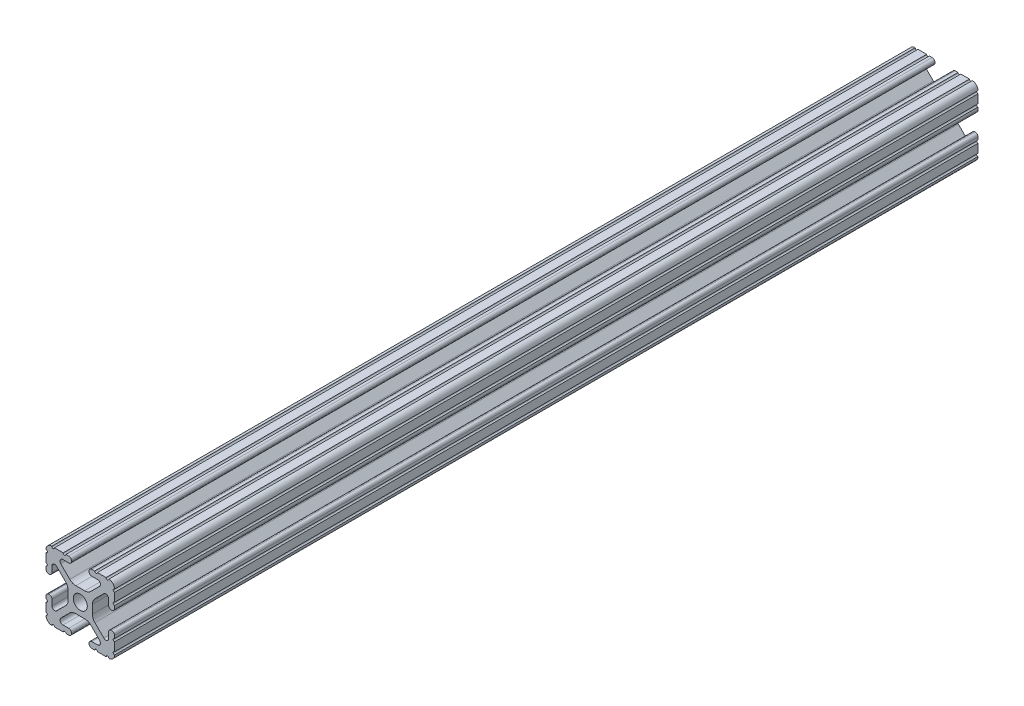
from build123d import *

# Parameters (mm, degrees)
SKETCH1_R      = 2.6035
EXTRUDE1_DEPTH = 160


with BuildPart() as part:
    # Sketch1 → Extrude1 (new body, symmetric)
    with BuildSketch(Plane.XY):
        with BuildLine():
            Line((-7.207036008, 8.724370562), (-3.898272566, 5.423169045))
            ThreePointArc((-3.898272566, 5.423169045), (-2.869120213, 4.736787962), (-1.655778399, 4.4958))
            Line((-1.655778399, 4.4958), (1.655778399, 4.4958))
            ThreePointArc((1.655778399, 4.4958), (2.869120213, 4.736787962), (3.898272566, 5.423169045))
            Line((3.898272566, 5.423169045), (7.207036008, 8.724370562))
            ThreePointArc((7.207036008, 8.724370562), (7.432222385, 9.85140422), (6.476788598, 10.4902))
            Line((6.476788598, 10.4902), (4.287512407, 10.4902))
            ThreePointArc((4.287512407, 10.4902), (3.54574862, 10.79744862), (3.2385, 11.539212407))
            Line((3.2385, 11.539212407), (3.2385, 11.650987593))
            ThreePointArc((3.2385, 11.650987593), (3.54574862, 12.39275138), (4.287512407, 12.7))
            Line((4.287512407, 12.7), (5.317126718, 12.7))
            ThreePointArc((5.317126718, 12.7), (5.825126718, 12.192), (6.333126718, 12.7))
            Line((6.333126718, 12.7), (9.550443118, 12.7))
            ThreePointArc((9.550443118, 12.7), (10.058366869, 12.192000006), (10.566443095, 12.699847501))
            ThreePointArc((10.566443095, 12.699847501), (12.082537762, 12.08250727), (12.699846982, 10.566399977))
            ThreePointArc((12.699846982, 10.566399977), (12.192000006, 10.058323491), (12.7, 9.5504))
            Line((12.7, 9.5504), (12.7, 6.3330836))
            ThreePointArc((12.7, 6.3330836), (12.192, 5.8250836), (12.7, 5.3170836))
            Line((12.7, 5.3170836), (12.7, 4.287469289))
            ThreePointArc((12.7, 4.287469289), (12.39275138, 3.545705502), (11.650987593, 3.238456882))
            Line((11.650987593, 3.238456882), (11.539212407, 3.238456882))
            ThreePointArc((11.539212407, 3.238456882), (10.79744862, 3.545705502), (10.4902, 4.287469289))
            Line((10.4902, 4.287469289), (10.4902, 6.402089023))
            ThreePointArc((10.4902, 6.402089023), (9.856505071, 7.351067942), (8.737131347, 7.129408934))
            Line((8.737131347, 7.129408934), (5.441005833, 3.840816462))
            ThreePointArc((5.441005833, 3.840816462), (4.750877967, 2.809883091), (4.5085, 1.593185507))
            Line((4.5085, 1.593185507), (4.5085, -1.593185507))
            ThreePointArc((4.5085, -1.593185507), (4.750877967, -2.809883091), (5.441005833, -3.840816462))
            Line((5.441005833, -3.840816462), (8.737131347, -7.129408934))
            ThreePointArc((8.737131347, -7.129408934), (9.856505071, -7.351067942), (10.4902, -6.402089023))
            Line((10.4902, -6.402089023), (10.4902, -4.287469289))
            ThreePointArc((10.4902, -4.287469289), (10.79744862, -3.545705502), (11.539212407, -3.238456882))
            Line((11.539212407, -3.238456882), (11.650987593, -3.238456882))
            ThreePointArc((11.650987593, -3.238456882), (12.39275138, -3.545705502), (12.7, -4.287469289))
            Line((12.7, -4.287469289), (12.7, -5.3170836))
            ThreePointArc((12.7, -5.3170836), (12.192, -5.8250836), (12.7, -6.3330836))
            Line((12.7, -6.3330836), (12.7, -9.5504))
            ThreePointArc((12.7, -9.5504), (12.192000006, -10.058323491), (12.699846982, -10.566399977))
            ThreePointArc((12.699846982, -10.566399977), (12.082537762, -12.08250727), (10.566443095, -12.699847501))
            ThreePointArc((10.566443095, -12.699847501), (10.058366869, -12.192000006), (9.550443118, -12.7))
            Line((9.550443118, -12.7), (6.333126718, -12.7))
            ThreePointArc((6.333126718, -12.7), (5.825126718, -12.192), (5.317126718, -12.7))
            Line((5.317126718, -12.7), (4.287512407, -12.7))
            ThreePointArc((4.287512407, -12.7), (3.54574862, -12.39275138), (3.2385, -11.650987593))
            Line((3.2385, -11.650987593), (3.2385, -11.539212407))
            ThreePointArc((3.2385, -11.539212407), (3.54574862, -10.79744862), (4.287512407, -10.4902))
            Line((4.287512407, -10.4902), (6.416408329, -10.4902))
            ThreePointArc((6.416408329, -10.4902), (7.41473083, -9.822813117), (7.179650497, -8.645192506))
            Line((7.179650497, -8.645192506), (3.952270251, -5.423690499))
            ThreePointArc((3.952270251, -5.423690499), (2.922936451, -4.736929036), (1.709253557, -4.4958))
            Line((1.709253557, -4.4958), (-1.709253557, -4.4958))
            ThreePointArc((-1.709253557, -4.4958), (-2.922936451, -4.736929036), (-3.952270251, -5.423690499))
            Line((-3.952270251, -5.423690499), (-7.179650497, -8.645192506))
            ThreePointArc((-7.179650497, -8.645192506), (-7.41473083, -9.822813117), (-6.416408329, -10.4902))
            Line((-6.416408329, -10.4902), (-4.287512407, -10.4902))
            ThreePointArc((-4.287512407, -10.4902), (-3.54574862, -10.79744862), (-3.2385, -11.539212407))
            Line((-3.2385, -11.539212407), (-3.2385, -11.650987593))
            ThreePointArc((-3.2385, -11.650987593), (-3.54574862, -12.39275138), (-4.287512407, -12.7))
            Line((-4.287512407, -12.7), (-5.317126718, -12.7))
            ThreePointArc((-5.317126718, -12.7), (-5.825126718, -12.192), (-6.333126718, -12.7))
            Line((-6.333126718, -12.7), (-9.550443118, -12.7))
            ThreePointArc((-9.550443118, -12.7), (-10.058366869, -12.192000006), (-10.566443095, -12.699847501))
            ThreePointArc((-10.566443095, -12.699847501), (-12.082537762, -12.08250727), (-12.699846982, -10.566399977))
            ThreePointArc((-12.699846982, -10.566399977), (-12.192000006, -10.058323491), (-12.7, -9.5504))
            Line((-12.7, -9.5504), (-12.7, -6.3330836))
            ThreePointArc((-12.7, -6.3330836), (-12.192, -5.8250836), (-12.7, -5.3170836))
            Line((-12.7, -5.3170836), (-12.7, -4.287469289))
            ThreePointArc((-12.7, -4.287469289), (-12.39275138, -3.545705502), (-11.650987593, -3.238456882))
            Line((-11.650987593, -3.238456882), (-11.539212407, -3.238456882))
            ThreePointArc((-11.539212407, -3.238456882), (-10.79744862, -3.545705502), (-10.4902, -4.287469289))
            Line((-10.4902, -4.287469289), (-10.4902, -6.402089023))
            ThreePointArc((-10.4902, -6.402089023), (-9.856505071, -7.351067942), (-8.737131347, -7.129408934))
            Line((-8.737131347, -7.129408934), (-5.441005833, -3.840816462))
            ThreePointArc((-5.441005833, -3.840816462), (-4.750877967, -2.809883091), (-4.5085, -1.593185507))
            Line((-4.5085, -1.593185507), (-4.5085, 1.593185507))
            ThreePointArc((-4.5085, 1.593185507), (-4.750877967, 2.809883091), (-5.441005833, 3.840816462))
            Line((-5.441005833, 3.840816462), (-8.737131347, 7.129408934))
            ThreePointArc((-8.737131347, 7.129408934), (-9.856505071, 7.351067942), (-10.4902, 6.402089023))
            Line((-10.4902, 6.402089023), (-10.4902, 4.287469289))
            ThreePointArc((-10.4902, 4.287469289), (-10.79744862, 3.545705502), (-11.539212407, 3.238456882))
            Line((-11.539212407, 3.238456882), (-11.650987593, 3.238456882))
            ThreePointArc((-11.650987593, 3.238456882), (-12.39275138, 3.545705502), (-12.7, 4.287469289))
            Line((-12.7, 4.287469289), (-12.7, 5.3170836))
            ThreePointArc((-12.7, 5.3170836), (-12.192, 5.8250836), (-12.7, 6.3330836))
            Line((-12.7, 6.3330836), (-12.7, 9.5504))
            ThreePointArc((-12.7, 9.5504), (-12.192000006, 10.058323491), (-12.699846982, 10.566399977))
            ThreePointArc((-12.699846982, 10.566399977), (-12.082537762, 12.08250727), (-10.566443095, 12.699847501))
            ThreePointArc((-10.566443095, 12.699847501), (-10.058366869, 12.192000006), (-9.550443118, 12.7))
            Line((-9.550443118, 12.7), (-6.333126718, 12.7))
            ThreePointArc((-6.333126718, 12.7), (-5.825126718, 12.192), (-5.317126718, 12.7))
            Line((-5.317126718, 12.7), (-4.287512407, 12.7))
            ThreePointArc((-4.287512407, 12.7), (-3.54574862, 12.39275138), (-3.2385, 11.650987593))
            Line((-3.2385, 11.650987593), (-3.2385, 11.539212407))
            ThreePointArc((-3.2385, 11.539212407), (-3.54574862, 10.79744862), (-4.287512407, 10.4902))
            Line((-4.287512407, 10.4902), (-6.476788598, 10.4902))
            ThreePointArc((-6.476788598, 10.4902), (-7.432222385, 9.85140422), (-7.207036008, 8.724370562))
        make_face()
        Circle(SKETCH1_R, mode=Mode.SUBTRACT)
    extrude(amount=EXTRUDE1_DEPTH, both=True)


solid = part.part
